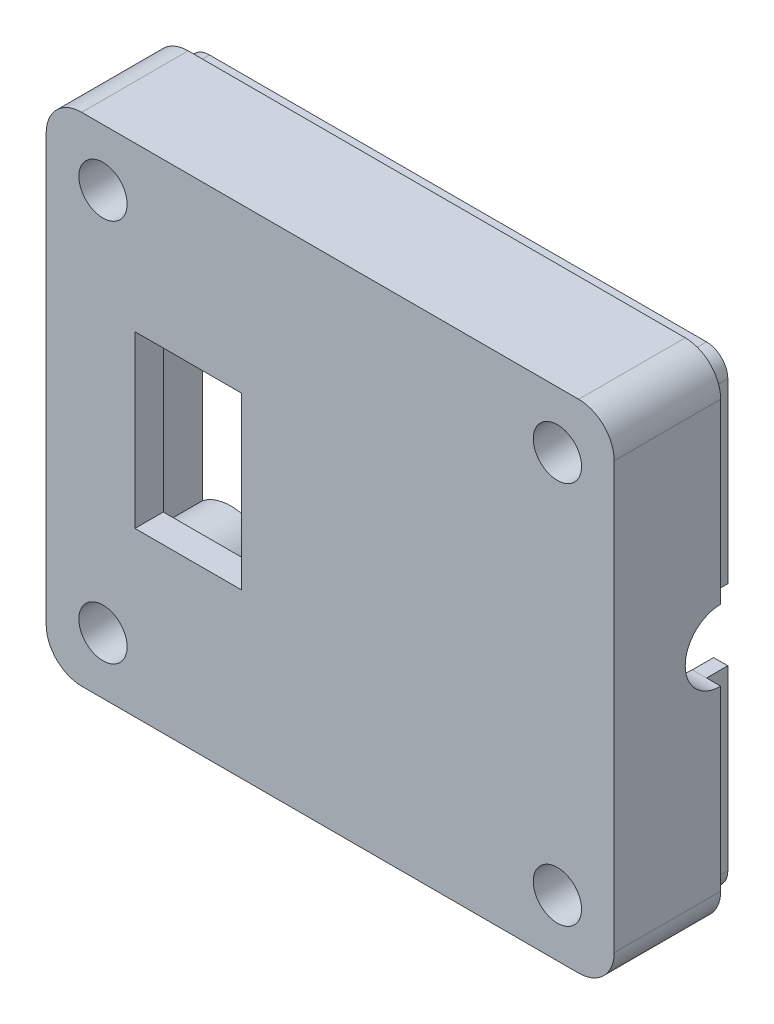
from build123d import *

# Parameters (mm, degrees)
ESQUISSE1_W             = 40
ESQUISSE1_H             = 35
ESQUISSE1_W_2           = 36
ESQUISSE1_H_2           = 31
BOSS_EXTRU_1_DEPTH      = 5.5
ESQUISSE2_W             = 40
ESQUISSE2_H             = 35
BOSS_EXTRU_2_DEPTH      = 2
ENL_V_MAT_EXTRU_1_REACH = 42
BOSS_EXTRU_3_DEPTH      = 7
ENL_V_MAT_EXTRU_2_REACH = 11
ESQUISSE9_W             = 7.5
ESQUISSE9_H             = 12
D_GAGEMENT_M31_D        = 3.4
CONG_1_R                = 2.5
BOSS_EXTRU_6_DEPTH      = 1.5


with BuildPart() as part:
    # Esquisse1 → Boss.-Extru.1 (new body)
    with BuildSketch(Plane.XY):
        with Locations((16.877269095, -24.858015503)):
            Rectangle(ESQUISSE1_W, ESQUISSE1_H)
        with Locations((16.877269095, -24.858015503)):
            Rectangle(ESQUISSE1_W_2, ESQUISSE1_H_2, mode=Mode.SUBTRACT)
    extrude(amount=BOSS_EXTRU_1_DEPTH)

    # Esquisse2 → Boss.-Extru.2 (add)
    with BuildSketch(Plane.XY.offset(5.5)):
        with Locations((16.877269095, -24.858015503)):
            Rectangle(ESQUISSE2_W, ESQUISSE2_H)
    extrude(amount=BOSS_EXTRU_2_DEPTH)

    # Esquisse3 → Enlèv. mat.-Extru.1 (cut, up to next)
    with BuildSketch(Plane(origin=(36.877269095, 0, 0), x_dir=(0, 0, -1), z_dir=(1, 0, 0)), mode=Mode.PRIVATE) as enl_v_mat_extru_1_sk1:
        with BuildLine():
            Line((0, -22.358015503), (0, -27.358015503))
            ThreePointArc((0, -27.358015503), (-2.5, -24.858015503), (0, -22.358015503))
        make_face()
    enl_v_mat_extru_1_tool1 = extrude(enl_v_mat_extru_1_sk1.sketch, amount=-ENL_V_MAT_EXTRU_1_REACH, mode=Mode.PRIVATE) & part.part
    add(enl_v_mat_extru_1_tool1.solids().sort_by_distance((36.877269, -24.858016, 1.061033))[0], mode=Mode.SUBTRACT)

    # Esquisse4 → Boss.-Extru.3 (add)
    with BuildSketch(Plane(origin=(0, 0, 5.5), x_dir=(-1, 0, 0), z_dir=(0, 0, -1))):
        with BuildLine():
            ThreePointArc((-34.877269095, -13.919753195), (-30.579172056, -13.656112542), (-30.315531404, -9.358015503))
            Line((-30.315531404, -9.358015503), (-34.877269095, -9.358015503))
            Line((-34.877269095, -9.358015503), (-34.877269095, -13.919753195))
        make_face()
        with BuildLine():
            Line((-34.877269095, -32.858015503), (-17.877269095, -32.858015503))
            Line((-17.877269095, -32.858015503), (-17.877269095, -40.358015503))
            Line((-17.877269095, -40.358015503), (-15.877269095, -40.358015503))
            Line((-15.877269095, -40.358015503), (-15.877269095, -31.858015503))
            ThreePointArc((-15.877269095, -31.858015503), (-16.170162314, -31.150908722), (-16.877269095, -30.858015503))
            Line((-16.877269095, -30.858015503), (-34.877269095, -30.858015503))
            Line((-34.877269095, -30.858015503), (-34.877269095, -32.858015503))
        make_face()
        with BuildLine():
            Line((-34.877269095, -35.796277812), (-34.877269095, -40.358015503))
            Line((-34.877269095, -40.358015503), (-30.315531404, -40.358015503))
            ThreePointArc((-30.315531404, -40.358015503), (-30.579172056, -36.059918465), (-34.877269095, -35.796277812))
        make_face()
        with BuildLine():
            Line((-17.877269095, -16.858015503), (-34.877269095, -16.858015503))
            Line((-34.877269095, -16.858015503), (-34.877269095, -18.858015503))
            Line((-34.877269095, -18.858015503), (-16.877269095, -18.858015503))
            ThreePointArc((-16.877269095, -18.858015503), (-16.170162314, -18.565122285), (-15.877269095, -17.858015503))
            Line((-15.877269095, -17.858015503), (-15.877269095, -9.358015503))
            Line((-15.877269095, -9.358015503), (-17.877269095, -9.358015503))
            Line((-17.877269095, -9.358015503), (-17.877269095, -16.858015503))
        make_face()
        with BuildLine():
            Line((-3.439006787, -40.358015503), (1.122730905, -40.358015503))
            Line((1.122730905, -40.358015503), (1.122730905, -35.796277812))
            ThreePointArc((1.122730905, -35.796277812), (-3.175366134, -36.059918465), (-3.439006787, -40.358015503))
        make_face()
        with BuildLine():
            Line((1.122730905, -13.919753195), (1.122730905, -9.358015503))
            Line((1.122730905, -9.358015503), (-3.439006787, -9.358015503))
            ThreePointArc((-3.439006787, -9.358015503), (-3.175366134, -13.656112542), (1.122730905, -13.919753195))
        make_face()
    extrude(amount=BOSS_EXTRU_3_DEPTH)

    # Esquisse9 → Enlèv. mat.-Extru.2 (cut, up to next)
    with BuildSketch(Plane(origin=(6.5, 0, 7.5), x_dir=(-1, 0, 0), z_dir=(0, 0, -1)), mode=Mode.PRIVATE) as enl_v_mat_extru_2_sk1:
        with Locations((-0.377269095, -24.858015503)):
            Rectangle(ESQUISSE9_W, ESQUISSE9_H)
    enl_v_mat_extru_2_tool1 = extrude(enl_v_mat_extru_2_sk1.sketch, amount=ENL_V_MAT_EXTRU_2_REACH, mode=Mode.PRIVATE) & part.part
    add(enl_v_mat_extru_2_tool1.solids().sort_by_distance((6.877269, -24.858016, 7.5))[0], mode=Mode.SUBTRACT)

    # Dégagement M31 (through all)
    with Locations(Plane.XY.offset(7.5)):
        with Locations((0.877269095, -11.358015503), (32.877269095, -38.358015503), (32.877269095, -11.358015503), (0.877269095, -38.358015503)):
            Hole(D_GAGEMENT_M31_D / 2)

    # Congé1
    cong_1_edges = [part.edges().sort_by_distance(p)[0] for p in [
        (-3.122730905, -7.358015503, 3.75),
        (36.877269095, -7.358015503, 3.75),
        (36.877269095, -42.358015503, 3.75),
        (-3.122730905, -42.358015503, 3.75),
    ]]
    fillet(cong_1_edges, radius=CONG_1_R)

    # Esquisse13 → Boss.-Extru.6 (add)
    with BuildSketch(Plane(origin=(0, 0, 0), x_dir=(-1, 0, 0), z_dir=(0, 0, -1))):
        with BuildLine():
            Line((-35.877269095, -27.358015503), (-34.877269095, -27.358015503))
            Line((-34.877269095, -27.358015503), (-34.877269095, -39.858015503))
            ThreePointArc((-34.877269095, -39.858015503), (-34.730822486, -40.211568894), (-34.377269095, -40.358015503))
            Line((-34.377269095, -40.358015503), (0.622730905, -40.358015503))
            ThreePointArc((0.622730905, -40.358015503), (0.976284295, -40.211568894), (1.122730905, -39.858015503))
            Line((1.122730905, -39.858015503), (1.122730905, -9.861767147))
            ThreePointArc((1.122730905, -9.861767147), (0.975185464, -9.505560944), (0.618979261, -9.358015503))
            Line((0.618979261, -9.358015503), (-34.377269095, -9.358015503))
            ThreePointArc((-34.377269095, -9.358015503), (-34.730822486, -9.504462113), (-34.877269095, -9.858015503))
            Line((-34.877269095, -9.858015503), (-34.877269095, -22.358015503))
            Line((-34.877269095, -22.358015503), (-35.877269095, -22.358015503))
            Line((-35.877269095, -22.358015503), (-35.877269095, -9.858015503))
            ThreePointArc((-35.877269095, -9.858015503), (-35.437929267, -8.797355332), (-34.377269095, -8.358015503))
            Line((-34.377269095, -8.358015503), (0.622730905, -8.358015503))
            ThreePointArc((0.622730905, -8.358015503), (1.683391077, -8.797355332), (2.122730905, -9.858015503))
            Line((2.122730905, -9.858015503), (2.122730905, -39.858015503))
            ThreePointArc((2.122730905, -39.858015503), (1.683391077, -40.918675675), (0.622730905, -41.358015503))
            Line((0.622730905, -41.358015503), (-34.377269095, -41.358015503))
            ThreePointArc((-34.377269095, -41.358015503), (-35.437929267, -40.918675675), (-35.877269095, -39.858015503))
            Line((-35.877269095, -39.858015503), (-35.877269095, -27.358015503))
        make_face()
    extrude(amount=BOSS_EXTRU_6_DEPTH)


solid = part.part
